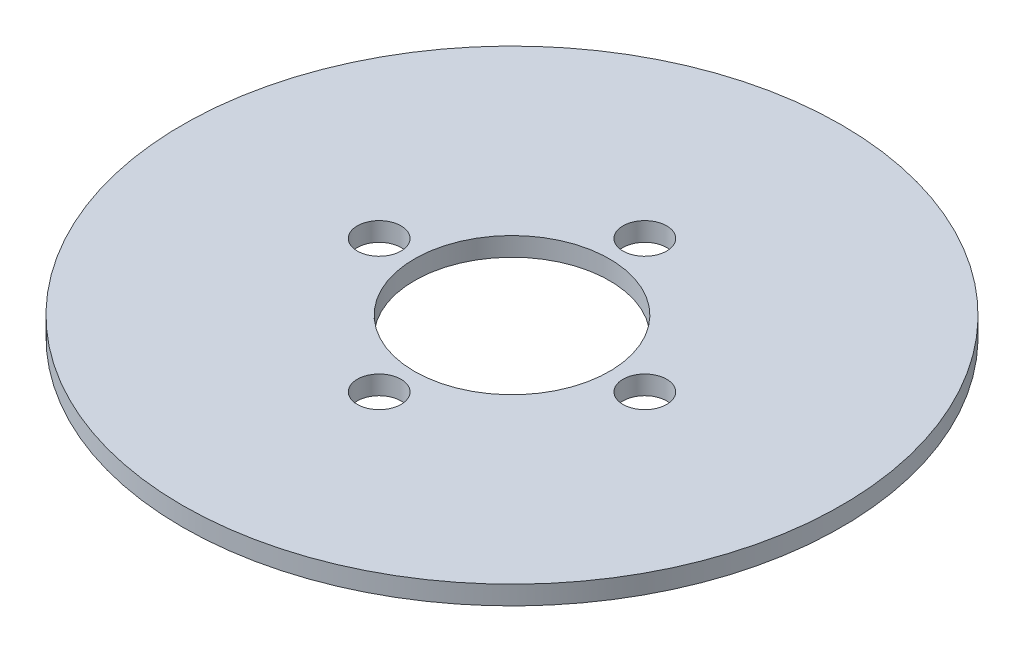
from build123d import *

# Parameters (mm, degrees)
SKETCH1_R           = 49
SKETCH1_R_2         = 14.5
SKETCH1_R_3         = 3.25
BOSS_EXTRUDE1_DEPTH = 1.4


with BuildPart() as part:
    # Sketch1 → Boss-Extrude1 (new body, symmetric)
    with BuildSketch(Plane(origin=(0, 0, 0), x_dir=(1, 0, 0), z_dir=(0, 1, 0))):
        Circle(SKETCH1_R)
        Circle(SKETCH1_R_2, mode=Mode.SUBTRACT)
        with Locations((0, 19.75)):
            Circle(SKETCH1_R_3, mode=Mode.SUBTRACT)
        with Locations((19.75, 0)):
            Circle(SKETCH1_R_3, mode=Mode.SUBTRACT)
        with Locations((0, -19.75)):
            Circle(SKETCH1_R_3, mode=Mode.SUBTRACT)
        with Locations((-19.75, 0)):
            Circle(SKETCH1_R_3, mode=Mode.SUBTRACT)
    extrude(amount=BOSS_EXTRUDE1_DEPTH, both=True)


solid = part.part
